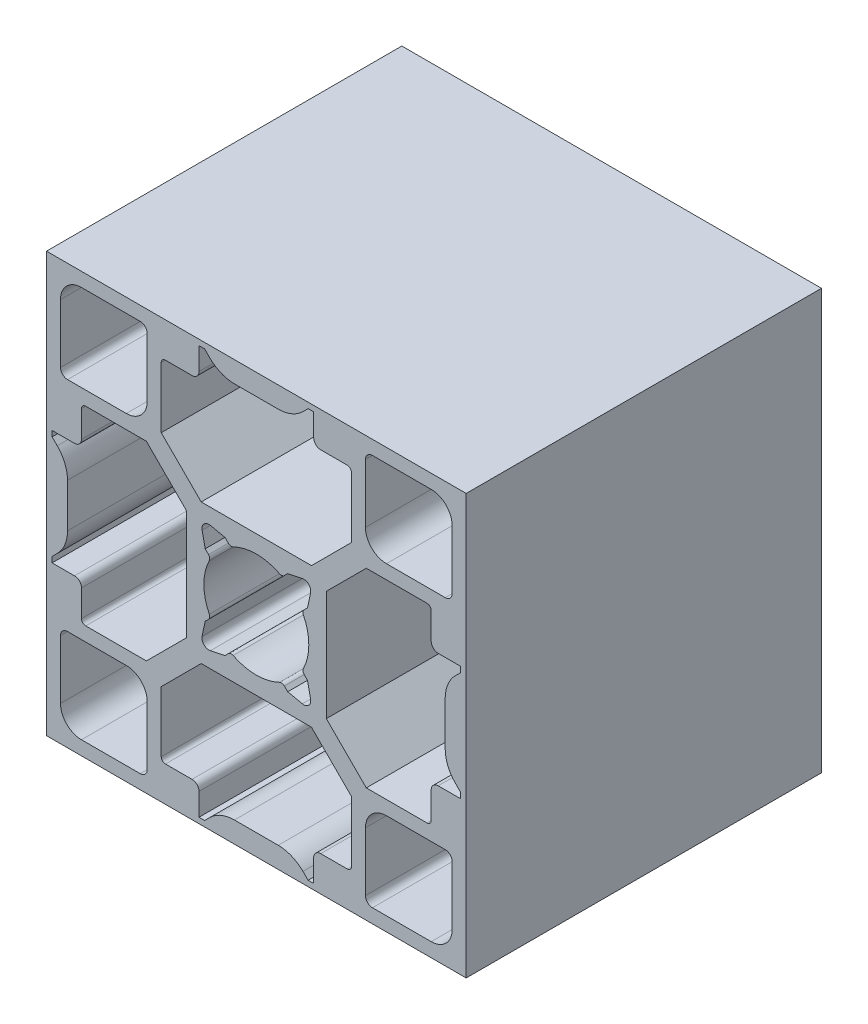
from build123d import *

# Parameters (mm, degrees)
SKETCH1_W        = 30
SKETCH1_H        = 30
EXTRUSION4_DEPTH = 25.4


with BuildPart() as part:
    # Sketch1 → Extrusion4 (new body)
    with BuildSketch(Plane.XY):
        with Locations((-8e-09, -2.5e-08)):
            Rectangle(SKETCH1_W, SKETCH1_H)
        with BuildLine():
            Line((7.799995412, -13.500000015), (7.799995412, -9.299995445))
            ThreePointArc((7.799995412, -9.299995445), (8.239335242, -8.239335275), (9.299995412, -7.799995445))
            Line((9.299995412, -7.799995445), (13.499999982, -7.799995445))
            ThreePointArc((13.499999982, -7.799995445), (13.853553372, -7.946442055), (13.999999982, -8.299995445))
            Line((13.999999982, -8.299995445), (13.999999982, -12.500000015))
            ThreePointArc((13.999999982, -12.500000015), (13.560660152, -13.560660185), (12.499999982, -14.000000015))
            Line((12.499999982, -14.000000015), (8.299995412, -14.000000015))
            ThreePointArc((8.299995412, -14.000000015), (7.946442022, -13.853553405), (7.799995412, -13.500000015))
        make_face(mode=Mode.SUBTRACT)
        with BuildLine():
            Line((13.499999982, 7.799995395), (9.299995412, 7.799995395))
            ThreePointArc((9.299995412, 7.799995395), (8.239335242, 8.239335225), (7.799995412, 9.299995395))
            Line((7.799995412, 9.299995395), (7.799995412, 13.499999965))
            ThreePointArc((7.799995412, 13.499999965), (7.946442022, 13.853553355), (8.299995412, 13.999999965))
            Line((8.299995412, 13.999999965), (12.499999982, 13.999999965))
            ThreePointArc((12.499999982, 13.999999965), (13.560660152, 13.560660135), (13.999999982, 12.499999965))
            Line((13.999999982, 12.499999965), (13.999999982, 8.299995395))
            ThreePointArc((13.999999982, 8.299995395), (13.853553372, 7.946442005), (13.499999982, 7.799995395))
        make_face(mode=Mode.SUBTRACT)
        with BuildLine():
            Line((-13.499999998, -7.799995445), (-9.299995428, -7.799995445))
            ThreePointArc((-9.299995428, -7.799995445), (-8.239335258, -8.239335275), (-7.799995428, -9.299995445))
            Line((-7.799995428, -9.299995445), (-7.799995428, -13.500000015))
            ThreePointArc((-7.799995428, -13.500000015), (-7.946442038, -13.853553405), (-8.299995428, -14.000000015))
            Line((-8.299995428, -14.000000015), (-12.499999998, -14.000000015))
            ThreePointArc((-12.499999998, -14.000000015), (-13.560660168, -13.560660185), (-13.999999998, -12.500000015))
            Line((-13.999999998, -12.500000015), (-13.999999998, -8.299995445))
            ThreePointArc((-13.999999998, -8.299995445), (-13.853553388, -7.946442055), (-13.499999998, -7.799995445))
        make_face(mode=Mode.SUBTRACT)
        with BuildLine():
            Line((-7.799995428, 13.499999965), (-7.799995428, 9.299995395))
            ThreePointArc((-7.799995428, 9.299995395), (-8.239335258, 8.239335225), (-9.299995428, 7.799995395))
            Line((-9.299995428, 7.799995395), (-13.499999998, 7.799995395))
            ThreePointArc((-13.499999998, 7.799995395), (-13.853553388, 7.946442005), (-13.999999998, 8.299995395))
            Line((-13.999999998, 8.299995395), (-13.999999998, 12.499999965))
            ThreePointArc((-13.999999998, 12.499999965), (-13.560660168, 13.560660135), (-12.499999998, 13.999999965))
            Line((-12.499999998, 13.999999965), (-8.299995428, 13.999999965))
            ThreePointArc((-8.299995428, 13.999999965), (-7.946442038, 13.853553355), (-7.799995428, 13.499999965))
        make_face(mode=Mode.SUBTRACT)
        with BuildLine():
            Line((-3.285876608, 3.878886835), (-2.243073548, 3.657287075))
            Line((-2.243073548, 3.657287075), (-2.005134008, 3.419347535))
            ThreePointArc((-2.005134008, 3.419347535), (-1.841800007, 3.335474925), (-1.660187018, 3.362481085))
            ThreePointArc((-1.660187018, 3.362481085), (-2.3e-08, 3.749999985), (1.660186972, 3.362481085))
            ThreePointArc((1.660186972, 3.362481085), (1.841799961, 3.335474925), (2.005133962, 3.419347535))
            Line((2.005133962, 3.419347535), (2.243073502, 3.657287075))
            Line((2.243073502, 3.657287075), (3.285876562, 3.878886835))
            ThreePointArc((3.285876562, 3.878886835), (3.743361172, 3.743361195), (3.878886812, 3.285876585))
            Line((3.878886812, 3.285876585), (3.657287052, 2.243073525))
            Line((3.657287052, 2.243073525), (3.419347512, 2.005133985))
            ThreePointArc((3.419347512, 2.005133985), (3.335474902, 1.841799984), (3.362481062, 1.660186995))
            ThreePointArc((3.362481062, 1.660186995), (3.749999954, -2e-09), (3.362481062, -1.660186995))
            ThreePointArc((3.362481062, -1.660186995), (3.335474902, -1.841799984), (3.419347512, -2.005133985))
            Line((3.419347512, -2.005133985), (3.657287052, -2.243073525))
            Line((3.657287052, -2.243073525), (3.878886812, -3.285876585))
            ThreePointArc((3.878886812, -3.285876585), (3.743361172, -3.743361195), (3.285876562, -3.878886835))
            Line((3.285876562, -3.878886835), (2.243073502, -3.657287075))
            Line((2.243073502, -3.657287075), (2.005133962, -3.419347535))
            ThreePointArc((2.005133962, -3.419347535), (1.841799961, -3.335474925), (1.660186972, -3.362481085))
            ThreePointArc((1.660186972, -3.362481085), (-2.3e-08, -3.74999999), (-1.660187018, -3.362481085))
            ThreePointArc((-1.660187018, -3.362481085), (-1.841800007, -3.335474925), (-2.005134008, -3.419347535))
            Line((-2.005134008, -3.419347535), (-2.243073548, -3.657287075))
            Line((-2.243073548, -3.657287075), (-3.285876608, -3.878886835))
            ThreePointArc((-3.285876608, -3.878886835), (-3.743361218, -3.743361195), (-3.878886858, -3.285876585))
            Line((-3.878886858, -3.285876585), (-3.657287098, -2.243073525))
            Line((-3.657287098, -2.243073525), (-3.419347558, -2.005133985))
            ThreePointArc((-3.419347558, -2.005133985), (-3.335474948, -1.841799984), (-3.362481108, -1.660186995))
            ThreePointArc((-3.362481108, -1.660186995), (-3.750000021, -2e-09), (-3.362481108, 1.660186995))
            ThreePointArc((-3.362481108, 1.660186995), (-3.335474948, 1.841799984), (-3.419347558, 2.005133985))
            Line((-3.419347558, 2.005133985), (-3.657287098, 2.243073525))
            Line((-3.657287098, 2.243073525), (-3.878886858, 3.285876585))
            ThreePointArc((-3.878886858, 3.285876585), (-3.743361218, 3.743361195), (-3.285876608, 3.878886835))
        make_face(mode=Mode.SUBTRACT)
        with BuildLine():
            Line((-6.799995418, -7.860655625), (-3.941497998, -5.002158195))
            Line((-3.941497998, -5.002158195), (3.941497992, -5.002158195))
            Line((3.941497992, -5.002158195), (6.799995422, -7.860655625))
            Line((6.799995422, -7.860655625), (6.799995422, -12.199996975))
            ThreePointArc((6.799995422, -12.199996975), (6.712130925, -12.412130132), (6.500000002, -12.500000025))
            Line((6.500000002, -12.500000025), (4.599998472, -12.500000025))
            ThreePointArc((4.599998472, -12.500000025), (4.246445082, -12.646446635), (4.099998472, -13.000000025))
            Line((4.099998472, -13.000000025), (4.099998472, -14.600000025))
            Line((4.099998472, -14.600000025), (3.699990832, -14.600000025))
            Line((3.699990832, -14.600000025), (3.332307072, -14.232291555))
            ThreePointArc((3.332307072, -14.232291555), (2.521228054, -13.690316336), (1.564480612, -13.499999115))
            Line((1.564480612, -13.499999115), (-5.8e-08, -13.499999185))
            Line((-5.8e-08, -13.499999185), (-1.564449118, -13.499999135))
            ThreePointArc((-1.564449118, -13.499999135), (-2.521158976, -13.690300794), (-3.332218038, -14.232234065))
            Line((-3.332218038, -14.232234065), (-3.699983218, -14.600000025))
            Line((-3.699983218, -14.600000025), (-4.099998468, -14.600000025))
            Line((-4.099998468, -14.600000025), (-4.099998468, -13.000000025))
            ThreePointArc((-4.099998468, -13.000000025), (-4.246445078, -12.646446635), (-4.599998468, -12.500000025))
            Line((-4.599998468, -12.500000025), (-6.499999998, -12.500000025))
            ThreePointArc((-6.499999998, -12.500000025), (-6.712130926, -12.412130137), (-6.799995418, -12.199996975))
            Line((-6.799995418, -12.199996975), (-6.799995418, -7.860655625))
        make_face(mode=Mode.SUBTRACT)
        with BuildLine():
            Line((-7.860655608, 6.799995385), (-5.002158178, 3.941497965))
            Line((-5.002158178, 3.941497965), (-5.002158178, -3.941498025))
            Line((-5.002158178, -3.941498025), (-7.860655608, -6.799995455))
            Line((-7.860655608, -6.799995455), (-12.199996958, -6.799995455))
            ThreePointArc((-12.199996958, -6.799995455), (-12.412130115, -6.712130958), (-12.500000008, -6.500000035))
            Line((-12.500000008, -6.500000035), (-12.500000008, -4.599998505))
            ThreePointArc((-12.500000008, -4.599998505), (-12.646446618, -4.246445115), (-13.000000008, -4.099998505))
            Line((-13.000000008, -4.099998505), (-14.600000008, -4.099998505))
            Line((-14.600000008, -4.099998505), (-14.600000008, -3.699990865))
            Line((-14.600000008, -3.699990865), (-14.232291538, -3.332307105))
            ThreePointArc((-14.232291538, -3.332307105), (-13.690316319, -2.521228087), (-13.499999098, -1.564480645))
            Line((-13.499999098, -1.564480645), (-13.499999168, 2.5e-08))
            Line((-13.499999168, 2.5e-08), (-13.499999118, 1.564449085))
            ThreePointArc((-13.499999118, 1.564449085), (-13.690300777, 2.521158943), (-14.232234048, 3.332218005))
            Line((-14.232234048, 3.332218005), (-14.600000008, 3.699983185))
            Line((-14.600000008, 3.699983185), (-14.600000008, 4.099998435))
            Line((-14.600000008, 4.099998435), (-13.000000008, 4.099998435))
            ThreePointArc((-13.000000008, 4.099998435), (-12.646446618, 4.246445045), (-12.500000008, 4.599998435))
            Line((-12.500000008, 4.599998435), (-12.500000008, 6.499999965))
            ThreePointArc((-12.500000008, 6.499999965), (-12.41213012, 6.712130893), (-12.199996958, 6.799995385))
            Line((-12.199996958, 6.799995385), (-7.860655608, 6.799995385))
        make_face(mode=Mode.SUBTRACT)
        with BuildLine():
            Line((6.799995402, 7.860655575), (3.941497982, 5.002158145))
            Line((3.941497982, 5.002158145), (-3.941498008, 5.002158145))
            Line((-3.941498008, 5.002158145), (-6.799995438, 7.860655575))
            Line((-6.799995438, 7.860655575), (-6.799995438, 12.199996925))
            ThreePointArc((-6.799995438, 12.199996925), (-6.712130941, 12.412130082), (-6.500000018, 12.499999975))
            Line((-6.500000018, 12.499999975), (-4.599998488, 12.499999975))
            ThreePointArc((-4.599998488, 12.499999975), (-4.246445098, 12.646446585), (-4.099998488, 12.999999975))
            Line((-4.099998488, 12.999999975), (-4.099998488, 14.599999975))
            Line((-4.099998488, 14.599999975), (-3.699990848, 14.599999975))
            Line((-3.699990848, 14.599999975), (-3.332307088, 14.232291505))
            ThreePointArc((-3.332307088, 14.232291505), (-2.52122807, 13.690316286), (-1.564480628, 13.499999065))
            Line((-1.564480628, 13.499999065), (4.2e-08, 13.499999135))
            Line((4.2e-08, 13.499999135), (1.564449102, 13.499999085))
            ThreePointArc((1.564449102, 13.499999085), (2.52115896, 13.690300744), (3.332218022, 14.232234015))
            Line((3.332218022, 14.232234015), (3.699983202, 14.599999975))
            Line((3.699983202, 14.599999975), (4.099998452, 14.599999975))
            Line((4.099998452, 14.599999975), (4.099998452, 12.999999975))
            ThreePointArc((4.099998452, 12.999999975), (4.246445062, 12.646446585), (4.599998452, 12.499999975))
            Line((4.599998452, 12.499999975), (6.499999982, 12.499999975))
            ThreePointArc((6.499999982, 12.499999975), (6.71213091, 12.412130087), (6.799995402, 12.199996925))
            Line((6.799995402, 12.199996925), (6.799995402, 7.860655575))
        make_face(mode=Mode.SUBTRACT)
        with BuildLine():
            Line((7.860655592, -6.799995435), (5.002158162, -3.941498015))
            Line((5.002158162, -3.941498015), (5.002158162, 3.941497975))
            Line((5.002158162, 3.941497975), (7.860655592, 6.799995405))
            Line((7.860655592, 6.799995405), (12.199996942, 6.799995405))
            ThreePointArc((12.199996942, 6.799995405), (12.412130099, 6.712130908), (12.499999992, 6.499999985))
            Line((12.499999992, 6.499999985), (12.499999992, 4.599998455))
            ThreePointArc((12.499999992, 4.599998455), (12.646446602, 4.246445065), (12.999999992, 4.099998455))
            Line((12.999999992, 4.099998455), (14.599999992, 4.099998455))
            Line((14.599999992, 4.099998455), (14.599999992, 3.699990815))
            Line((14.599999992, 3.699990815), (14.232291522, 3.332307055))
            ThreePointArc((14.232291522, 3.332307055), (13.690316303, 2.521228037), (13.499999082, 1.564480595))
            Line((13.499999082, 1.564480595), (13.499999152, -7.5e-08))
            Line((13.499999152, -7.5e-08), (13.499999102, -1.564449135))
            ThreePointArc((13.499999102, -1.564449135), (13.690300761, -2.521158993), (14.232234032, -3.332218055))
            Line((14.232234032, -3.332218055), (14.599999992, -3.699983235))
            Line((14.599999992, -3.699983235), (14.599999992, -4.099998485))
            Line((14.599999992, -4.099998485), (12.999999992, -4.099998485))
            ThreePointArc((12.999999992, -4.099998485), (12.646446602, -4.246445095), (12.499999992, -4.599998485))
            Line((12.499999992, -4.599998485), (12.499999992, -6.500000015))
            ThreePointArc((12.499999992, -6.500000015), (12.412130104, -6.712130943), (12.199996942, -6.799995435))
            Line((12.199996942, -6.799995435), (7.860655592, -6.799995435))
        make_face(mode=Mode.SUBTRACT)
    extrude(amount=EXTRUSION4_DEPTH)


solid = part.part
